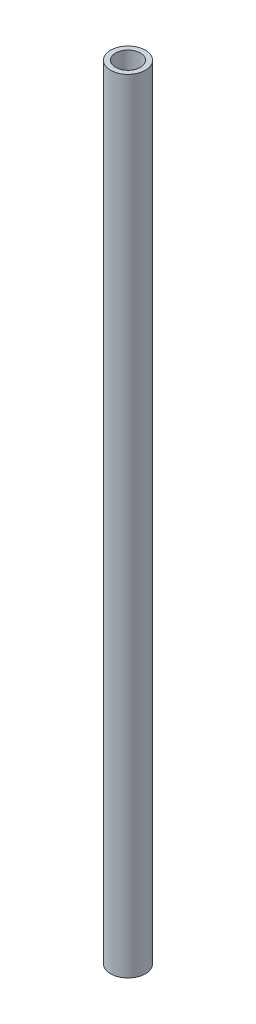
from build123d import *

# Parameters (mm, degrees)
SKETCH1_R           = 22.225
SKETCH1_R_2         = 15.875
BOSS_EXTRUDE1_DEPTH = 500


with BuildPart() as part:
    # Sketch1 → Boss-Extrude1 (new body, symmetric)
    with BuildSketch(Plane(origin=(0, 0, 0), x_dir=(1, 0, 0), z_dir=(0, 1, 0))):
        Circle(SKETCH1_R)
        Circle(SKETCH1_R_2, mode=Mode.SUBTRACT)
    extrude(amount=BOSS_EXTRUDE1_DEPTH, both=True)


solid = part.part
